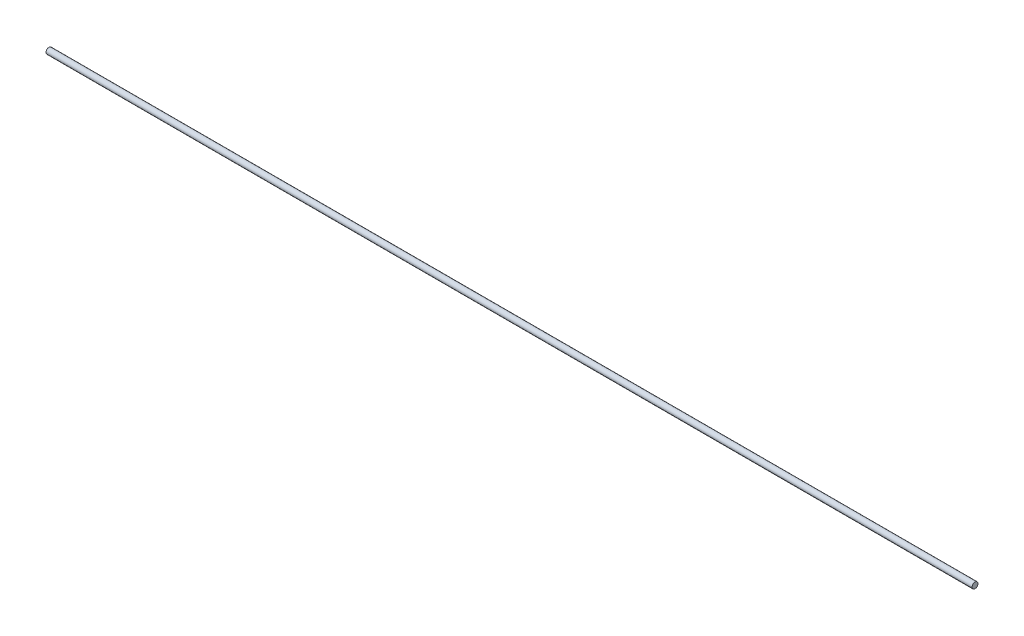
from build123d import *

# Parameters (mm, degrees)
SKETCH1_R           = 3
SKETCH1_R_2         = 0.003
BOSS_EXTRUDE1_DEPTH = 469


with BuildPart() as part:
    # Sketch1 → Boss-Extrude1 (new body, symmetric)
    with BuildSketch(Plane(origin=(0, 0, 0), x_dir=(0, 0, -1), z_dir=(1, 0, 0))):
        Circle(SKETCH1_R)
        Circle(SKETCH1_R_2, mode=Mode.SUBTRACT)
    extrude(amount=BOSS_EXTRUDE1_DEPTH, both=True)


solid = part.part
